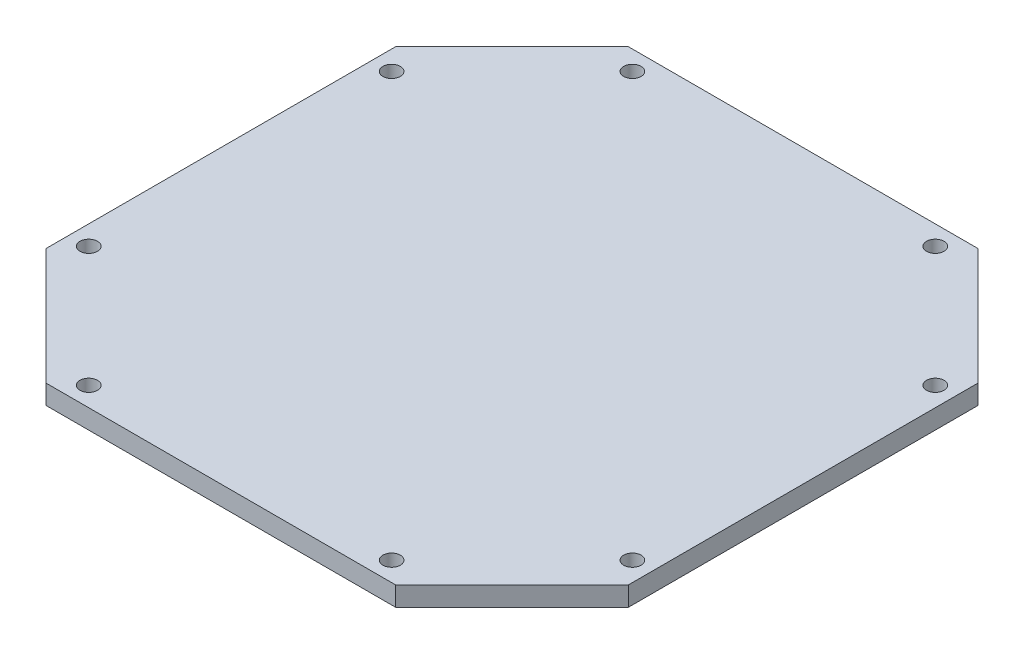
from build123d import *

# Parameters (mm, degrees)
BOSS_EXTRUDE1_DEPTH   = 10
F_1_0MM_DOWEL_HOLE1_D = 9


with BuildPart() as part:
    # Sketch1 → Boss-Extrude1 (new body)
    with BuildSketch(Plane(origin=(0, 0, 0), x_dir=(1, 0, 0), z_dir=(0, 1, 0))):
        Polygon((-146.091205212, 90.488599349), (-86.091205212, 150.488599349), (93.908794788, 150.488599349), (153.908794788, 90.488599349), (153.908794788, -89.511400651), (93.908794788, -149.511400651), (-86.091205212, -149.511400651), (-146.091205212, -89.511400651), align=None)
    extrude(amount=BOSS_EXTRUDE1_DEPTH)

    # Ø1.0mm Dowel Hole1 (through all)
    with Locations(Plane(origin=(0, 10, 0), x_dir=(1, 0, 0), z_dir=(0, 1, 0))):
        with Locations((-136.091205212, 78.488599349), (-74.091205212, 140.488599349), (81.908794788, 140.488599349), (143.908794788, 78.488599349), (143.908794788, -77.511400651), (81.908794788, -139.511400651), (-74.091205212, -139.511400651), (-136.091205212, -77.511400651)):
            Hole(F_1_0MM_DOWEL_HOLE1_D / 2)


solid = part.part
